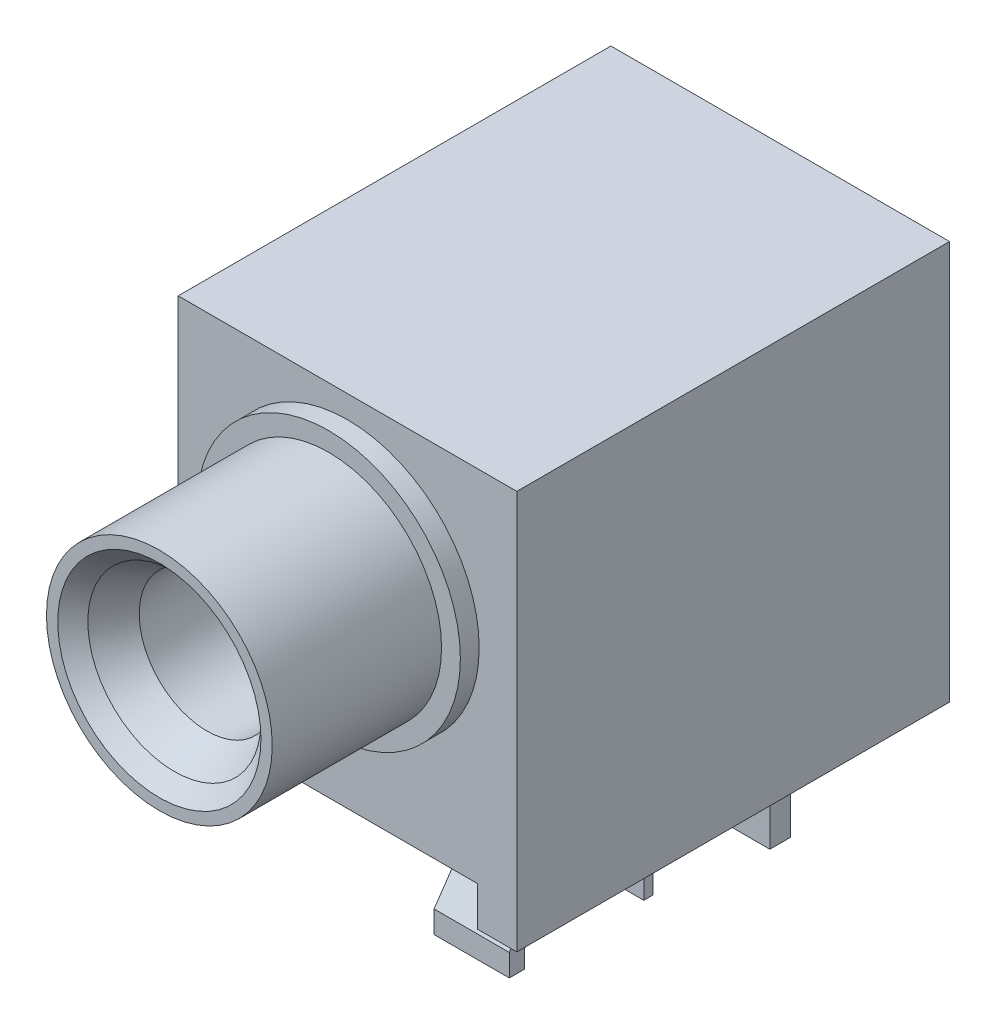
from build123d import *

# Parameters (mm, degrees)
BOSS_EXTRUDE1_DEPTH   = 11.5
SKETCH2_R             = 3.5
BOSS_EXTRUDE2_DEPTH   = 0.5
SKETCH3_R             = 3
BOSS_EXTRUDE3_DEPTH   = 4.5
BOSS_EXTRUDE4_DEPTH   = 1
SKETCH5_W             = 0.25
SKETCH5_H             = 5.05
BOSS_EXTRUDE4_2_DEPTH = 1
SKETCH5_W_2           = 0.55
SKETCH5_H_2           = 5.55
BOSS_EXTRUDE4_3_DEPTH = 1


with BuildPart() as part:
    # Sketch1 → Boss-Extrude1 (new body)
    with BuildSketch(Plane.XY):
        Polygon((-4.5, 10.6), (4.5, 10.6), (4.5, 0), (3.45, 0), (3.45, 1.05), (-3.45, 1.05), (-3.45, 0), (-4.5, 0), align=None)
    extrude(amount=-BOSS_EXTRUDE1_DEPTH)


with BuildPart() as body_2:
    # Sketch2 → Boss-Extrude2 (new body)
    with BuildSketch(Plane.XY):
        with Locations((0, 6.5)):
            Circle(SKETCH2_R)
    extrude(amount=BOSS_EXTRUDE2_DEPTH)

    # Sketch3 → Boss-Extrude3 (add)
    with BuildSketch(Plane.XY.offset(0.5)):
        with Locations((0, 6.5)):
            Circle(SKETCH3_R)
    extrude(amount=BOSS_EXTRUDE3_DEPTH)

    # Sketch4 → Cut-Revolve1 (revolve, cut)
    with BuildSketch(Plane(origin=(0, 6.5, 0), x_dir=(1, 0, 0), z_dir=(0, 1, 0))):
        Polygon((0, 0), (1.8, 0), (1.8, -3.733974596), (2.3, -4.6), (2.7, -5), (0, -5), align=None)
    revolve(axis=Axis((0, 6.5, 5), (0, 0, -1)), mode=Mode.SUBTRACT)


with BuildPart() as body_3:
    # Sketch5 → Boss-Extrude4 (new, symmetric)
    with BuildSketch(Plane(origin=(0, 0, 0), x_dir=(0, 0, -1), z_dir=(1, 0, 0))):
        Polygon((3.3, 1.05), (3.3, -1.255323904), (3.870369506, -2.581808326), (3.3, -3.410189816), (3.3, -4), (3.7, -4), (3.7, -3.534579776), (4.325091858, -2.626721766), (3.7, -1.172971866), (3.7, 1.05), align=None)
    extrude(amount=BOSS_EXTRUDE4_DEPTH, both=True)


with BuildPart() as body_4:
    # Sketch5 → Boss-Extrude4 2 (new, symmetric)
    with BuildSketch(Plane(origin=(0, 0, 0), x_dir=(0, 0, -1), z_dir=(1, 0, 0))):
        with Locations((7, -1.475)):
            Rectangle(SKETCH5_W, SKETCH5_H)
    extrude(amount=BOSS_EXTRUDE4_2_DEPTH, both=True)


with BuildPart() as body_5:
    # Sketch5 → Boss-Extrude4 3 (new, symmetric)
    with BuildSketch(Plane(origin=(0, 0, 0), x_dir=(0, 0, -1), z_dir=(1, 0, 0))):
        with Locations((10.5, -1.725)):
            Rectangle(SKETCH5_W_2, SKETCH5_H_2)
    extrude(amount=BOSS_EXTRUDE4_3_DEPTH, both=True)


solid = Compound([part.part, body_2.part, body_3.part, body_4.part, body_5.part])
